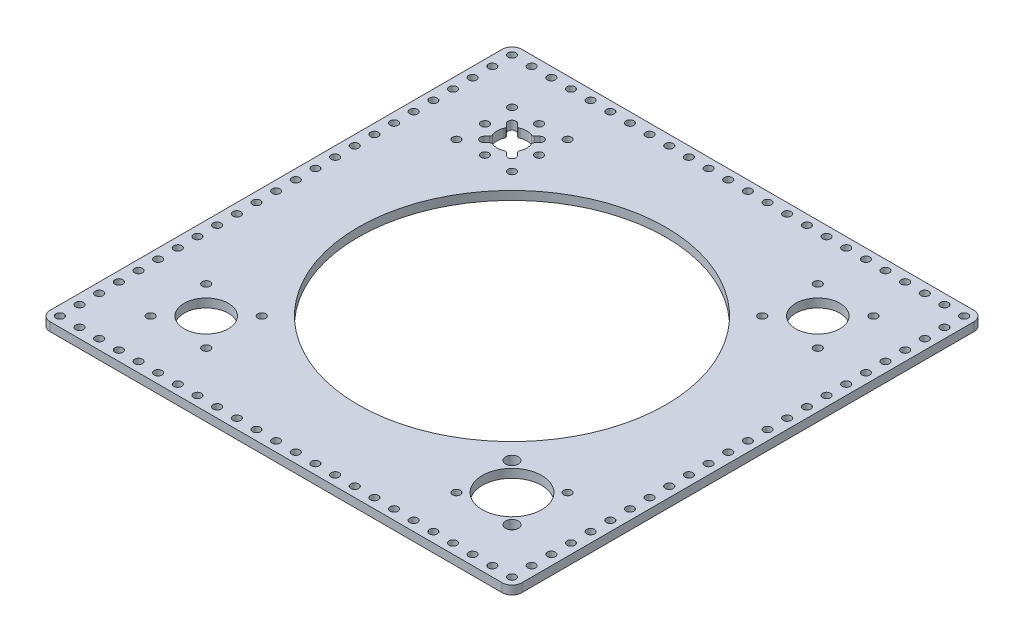
from build123d import *

# Parameters (mm, degrees)
SKETCH1_R           = 99.375000001
SKETCH1_R_2         = 2.5527
SKETCH1_R_3         = 19.177
SKETCH1_R_4         = 4.1275
SKETCH1_R_5         = 14.28115
ANDYMARK_BASE_DEPTH = 5.588


with BuildPart() as part:
    # Sketch1 → AndyMark Base (new body)
    with BuildSketch(Plane.XZ):
        with BuildLine():
            Line((0, -6.35), (0, -298.45))
            ThreePointArc((0, -298.45), (1.859871939, -302.940128061), (6.35, -304.8))
            Line((6.35, -304.8), (298.45, -304.8))
            ThreePointArc((298.45, -304.8), (302.940128061, -302.940128061), (304.8, -298.45))
            Line((304.8, -298.45), (304.8, -6.35))
            ThreePointArc((304.8, -6.35), (302.940128061, -1.859871939), (298.45, 0))
            Line((298.45, 0), (6.35, 0))
            ThreePointArc((6.35, 0), (1.859871939, -1.859871939), (0, -6.35))
        make_face()
        with Locations((152.4, -152.4)):
            Circle(SKETCH1_R, mode=Mode.SUBTRACT)
        with Locations((6.35, -298.45)):
            Circle(SKETCH1_R_2, mode=Mode.SUBTRACT)
        with Locations((19.05, -298.45)):
            Circle(SKETCH1_R_2, mode=Mode.SUBTRACT)
        with Locations((31.75, -298.45)):
            Circle(SKETCH1_R_2, mode=Mode.SUBTRACT)
        with Locations((44.45, -298.45)):
            Circle(SKETCH1_R_2, mode=Mode.SUBTRACT)
        with Locations((57.15, -298.45)):
            Circle(SKETCH1_R_2, mode=Mode.SUBTRACT)
        with Locations((69.85, -298.45)):
            Circle(SKETCH1_R_2, mode=Mode.SUBTRACT)
        with Locations((82.55, -298.45)):
            Circle(SKETCH1_R_2, mode=Mode.SUBTRACT)
        with Locations((95.25, -298.45)):
            Circle(SKETCH1_R_2, mode=Mode.SUBTRACT)
        with Locations((107.95, -298.45)):
            Circle(SKETCH1_R_2, mode=Mode.SUBTRACT)
        with Locations((120.65, -298.45)):
            Circle(SKETCH1_R_2, mode=Mode.SUBTRACT)
        with Locations((133.35, -298.45)):
            Circle(SKETCH1_R_2, mode=Mode.SUBTRACT)
        with Locations((146.05, -298.45)):
            Circle(SKETCH1_R_2, mode=Mode.SUBTRACT)
        with Locations((158.75, -298.45)):
            Circle(SKETCH1_R_2, mode=Mode.SUBTRACT)
        with Locations((171.45, -298.45)):
            Circle(SKETCH1_R_2, mode=Mode.SUBTRACT)
        with Locations((184.15, -298.45)):
            Circle(SKETCH1_R_2, mode=Mode.SUBTRACT)
        with Locations((196.85, -298.45)):
            Circle(SKETCH1_R_2, mode=Mode.SUBTRACT)
        with Locations((209.55, -298.45)):
            Circle(SKETCH1_R_2, mode=Mode.SUBTRACT)
        with Locations((222.25, -298.45)):
            Circle(SKETCH1_R_2, mode=Mode.SUBTRACT)
        with Locations((234.95, -298.45)):
            Circle(SKETCH1_R_2, mode=Mode.SUBTRACT)
        with Locations((247.65, -298.45)):
            Circle(SKETCH1_R_2, mode=Mode.SUBTRACT)
        with Locations((260.35, -298.45)):
            Circle(SKETCH1_R_2, mode=Mode.SUBTRACT)
        with Locations((273.05, -298.45)):
            Circle(SKETCH1_R_2, mode=Mode.SUBTRACT)
        with Locations((285.75, -298.45)):
            Circle(SKETCH1_R_2, mode=Mode.SUBTRACT)
        with Locations((298.45, -298.45)):
            Circle(SKETCH1_R_2, mode=Mode.SUBTRACT)
        with Locations((6.35, -6.35)):
            Circle(SKETCH1_R_2, mode=Mode.SUBTRACT)
        with Locations((19.05, -6.35)):
            Circle(SKETCH1_R_2, mode=Mode.SUBTRACT)
        with Locations((31.75, -6.35)):
            Circle(SKETCH1_R_2, mode=Mode.SUBTRACT)
        with Locations((44.45, -6.35)):
            Circle(SKETCH1_R_2, mode=Mode.SUBTRACT)
        with Locations((57.15, -6.35)):
            Circle(SKETCH1_R_2, mode=Mode.SUBTRACT)
        with Locations((69.85, -6.35)):
            Circle(SKETCH1_R_2, mode=Mode.SUBTRACT)
        with Locations((82.55, -6.35)):
            Circle(SKETCH1_R_2, mode=Mode.SUBTRACT)
        with Locations((95.25, -6.35)):
            Circle(SKETCH1_R_2, mode=Mode.SUBTRACT)
        with Locations((107.95, -6.35)):
            Circle(SKETCH1_R_2, mode=Mode.SUBTRACT)
        with Locations((120.65, -6.35)):
            Circle(SKETCH1_R_2, mode=Mode.SUBTRACT)
        with Locations((133.35, -6.35)):
            Circle(SKETCH1_R_2, mode=Mode.SUBTRACT)
        with Locations((146.05, -6.35)):
            Circle(SKETCH1_R_2, mode=Mode.SUBTRACT)
        with Locations((158.75, -6.35)):
            Circle(SKETCH1_R_2, mode=Mode.SUBTRACT)
        with Locations((171.45, -6.35)):
            Circle(SKETCH1_R_2, mode=Mode.SUBTRACT)
        with Locations((184.15, -6.35)):
            Circle(SKETCH1_R_2, mode=Mode.SUBTRACT)
        with Locations((196.85, -6.35)):
            Circle(SKETCH1_R_2, mode=Mode.SUBTRACT)
        with Locations((209.55, -6.35)):
            Circle(SKETCH1_R_2, mode=Mode.SUBTRACT)
        with Locations((222.25, -6.35)):
            Circle(SKETCH1_R_2, mode=Mode.SUBTRACT)
        with Locations((234.95, -6.35)):
            Circle(SKETCH1_R_2, mode=Mode.SUBTRACT)
        with Locations((247.65, -6.35)):
            Circle(SKETCH1_R_2, mode=Mode.SUBTRACT)
        with Locations((260.35, -6.35)):
            Circle(SKETCH1_R_2, mode=Mode.SUBTRACT)
        with Locations((273.05, -6.35)):
            Circle(SKETCH1_R_2, mode=Mode.SUBTRACT)
        with Locations((285.75, -6.35)):
            Circle(SKETCH1_R_2, mode=Mode.SUBTRACT)
        with Locations((298.45, -6.35)):
            Circle(SKETCH1_R_2, mode=Mode.SUBTRACT)
        with Locations((6.35, -285.75)):
            Circle(SKETCH1_R_2, mode=Mode.SUBTRACT)
        with Locations((298.45, -285.75)):
            Circle(SKETCH1_R_2, mode=Mode.SUBTRACT)
        with Locations((6.35, -273.05)):
            Circle(SKETCH1_R_2, mode=Mode.SUBTRACT)
        with Locations((298.45, -273.05)):
            Circle(SKETCH1_R_2, mode=Mode.SUBTRACT)
        with Locations((6.35, -260.35)):
            Circle(SKETCH1_R_2, mode=Mode.SUBTRACT)
        with Locations((298.45, -260.35)):
            Circle(SKETCH1_R_2, mode=Mode.SUBTRACT)
        with Locations((6.35, -247.65)):
            Circle(SKETCH1_R_2, mode=Mode.SUBTRACT)
        with Locations((298.45, -247.65)):
            Circle(SKETCH1_R_2, mode=Mode.SUBTRACT)
        with Locations((6.35, -234.95)):
            Circle(SKETCH1_R_2, mode=Mode.SUBTRACT)
        with Locations((298.45, -234.95)):
            Circle(SKETCH1_R_2, mode=Mode.SUBTRACT)
        with Locations((6.35, -222.25)):
            Circle(SKETCH1_R_2, mode=Mode.SUBTRACT)
        with Locations((298.45, -222.25)):
            Circle(SKETCH1_R_2, mode=Mode.SUBTRACT)
        with Locations((6.35, -209.55)):
            Circle(SKETCH1_R_2, mode=Mode.SUBTRACT)
        with Locations((298.45, -209.55)):
            Circle(SKETCH1_R_2, mode=Mode.SUBTRACT)
        with Locations((6.35, -196.85)):
            Circle(SKETCH1_R_2, mode=Mode.SUBTRACT)
        with Locations((298.45, -196.85)):
            Circle(SKETCH1_R_2, mode=Mode.SUBTRACT)
        with Locations((6.35, -184.15)):
            Circle(SKETCH1_R_2, mode=Mode.SUBTRACT)
        with Locations((298.45, -184.15)):
            Circle(SKETCH1_R_2, mode=Mode.SUBTRACT)
        with Locations((6.35, -171.45)):
            Circle(SKETCH1_R_2, mode=Mode.SUBTRACT)
        with Locations((298.45, -171.45)):
            Circle(SKETCH1_R_2, mode=Mode.SUBTRACT)
        with Locations((6.35, -158.75)):
            Circle(SKETCH1_R_2, mode=Mode.SUBTRACT)
        with Locations((298.45, -158.75)):
            Circle(SKETCH1_R_2, mode=Mode.SUBTRACT)
        with Locations((6.35, -146.05)):
            Circle(SKETCH1_R_2, mode=Mode.SUBTRACT)
        with Locations((298.45, -146.05)):
            Circle(SKETCH1_R_2, mode=Mode.SUBTRACT)
        with Locations((6.35, -133.35)):
            Circle(SKETCH1_R_2, mode=Mode.SUBTRACT)
        with Locations((298.45, -133.35)):
            Circle(SKETCH1_R_2, mode=Mode.SUBTRACT)
        with Locations((6.35, -120.65)):
            Circle(SKETCH1_R_2, mode=Mode.SUBTRACT)
        with Locations((298.45, -120.65)):
            Circle(SKETCH1_R_2, mode=Mode.SUBTRACT)
        with Locations((6.35, -107.95)):
            Circle(SKETCH1_R_2, mode=Mode.SUBTRACT)
        with Locations((298.45, -107.95)):
            Circle(SKETCH1_R_2, mode=Mode.SUBTRACT)
        with Locations((6.35, -95.25)):
            Circle(SKETCH1_R_2, mode=Mode.SUBTRACT)
        with Locations((298.45, -95.25)):
            Circle(SKETCH1_R_2, mode=Mode.SUBTRACT)
        with Locations((6.35, -82.55)):
            Circle(SKETCH1_R_2, mode=Mode.SUBTRACT)
        with Locations((298.45, -82.55)):
            Circle(SKETCH1_R_2, mode=Mode.SUBTRACT)
        with Locations((6.35, -69.85)):
            Circle(SKETCH1_R_2, mode=Mode.SUBTRACT)
        with Locations((298.45, -69.85)):
            Circle(SKETCH1_R_2, mode=Mode.SUBTRACT)
        with Locations((6.35, -57.15)):
            Circle(SKETCH1_R_2, mode=Mode.SUBTRACT)
        with Locations((298.45, -57.15)):
            Circle(SKETCH1_R_2, mode=Mode.SUBTRACT)
        with Locations((6.35, -44.45)):
            Circle(SKETCH1_R_2, mode=Mode.SUBTRACT)
        with Locations((298.45, -44.45)):
            Circle(SKETCH1_R_2, mode=Mode.SUBTRACT)
        with Locations((6.35, -31.75)):
            Circle(SKETCH1_R_2, mode=Mode.SUBTRACT)
        with Locations((298.45, -31.75)):
            Circle(SKETCH1_R_2, mode=Mode.SUBTRACT)
        with Locations((6.35, -19.05)):
            Circle(SKETCH1_R_2, mode=Mode.SUBTRACT)
        with Locations((298.45, -19.05)):
            Circle(SKETCH1_R_2, mode=Mode.SUBTRACT)
        with Locations((35.656670426, -35.656670426)):
            Circle(SKETCH1_R_2, mode=Mode.SUBTRACT)
        with Locations((71.57769491, -35.656670426)):
            Circle(SKETCH1_R_2, mode=Mode.SUBTRACT)
        with Locations((71.57769491, -71.57769491)):
            Circle(SKETCH1_R_2, mode=Mode.SUBTRACT)
        with Locations((269.143329574, -71.57769491)):
            Circle(SKETCH1_R_2, mode=Mode.SUBTRACT)
        with Locations((233.22230509, -35.656670426)):
            Circle(SKETCH1_R_2, mode=Mode.SUBTRACT)
        with Locations((269.143329574, -233.22230509)):
            Circle(SKETCH1_R_2, mode=Mode.SUBTRACT)
        with Locations((269.143329574, -269.143329574)):
            Circle(SKETCH1_R_2, mode=Mode.SUBTRACT)
        with Locations((233.22230509, -269.143329574)):
            Circle(SKETCH1_R_2, mode=Mode.SUBTRACT)
        with Locations((35.656670426, -269.143329574)):
            Circle(SKETCH1_R_2, mode=Mode.SUBTRACT)
        with Locations((35.656670426, -71.57769491)):
            Circle(SKETCH1_R_2, mode=Mode.SUBTRACT)
        with Locations((233.22230509, -233.22230509)):
            Circle(SKETCH1_R_2, mode=Mode.SUBTRACT)
        with Locations((35.656670426, -233.22230509)):
            Circle(SKETCH1_R_2, mode=Mode.SUBTRACT)
        with Locations((71.57769491, -233.22230509)):
            Circle(SKETCH1_R_2, mode=Mode.SUBTRACT)
        with Locations((71.57769491, -269.143329574)):
            Circle(SKETCH1_R_2, mode=Mode.SUBTRACT)
        with Locations((251.182817332, -53.617182668)):
            Circle(SKETCH1_R_3, mode=Mode.SUBTRACT)
        with Locations((233.22230509, -71.57769491)):
            Circle(SKETCH1_R_4, mode=Mode.SUBTRACT)
        with Locations((269.143329574, -35.656670426)):
            Circle(SKETCH1_R_4, mode=Mode.SUBTRACT)
        with Locations((251.182817332, -251.182817332)):
            Circle(SKETCH1_R_5, mode=Mode.SUBTRACT)
        with Locations((53.617182668, -53.617182668)):
            Circle(SKETCH1_R_5, mode=Mode.SUBTRACT)
        with Locations((53.617182668, -268.645317332)):
            Circle(SKETCH1_R_2, mode=Mode.SUBTRACT)
        with Locations((71.079682668, -251.182817332)):
            Circle(SKETCH1_R_2, mode=Mode.SUBTRACT)
        with Locations((53.617182668, -233.720317332)):
            Circle(SKETCH1_R_2, mode=Mode.SUBTRACT)
        with Locations((36.154682668, -251.182817332)):
            Circle(SKETCH1_R_2, mode=Mode.SUBTRACT)
        with BuildLine():
            Line((62.762572449, -256.718144152), (64.40247027, -258.358041972))
            ThreePointArc((64.40247027, -258.358041972), (64.40247027, -261.968104933), (60.792407309, -261.968104933))
            Line((60.792407309, -261.968104933), (59.152509488, -260.328207113))
            ThreePointArc((59.152509488, -260.328207113), (58.32939993, -259.891732251), (57.403160029, -259.992227509))
            ThreePointArc((57.403160029, -259.992227509), (53.617182668, -260.771317332), (49.831205307, -259.992227509))
            ThreePointArc((49.831205307, -259.992227509), (48.904965407, -259.891732251), (48.081855848, -260.328207113))
            Line((48.081855848, -260.328207113), (46.441958028, -261.968104933))
            ThreePointArc((46.441958028, -261.968104933), (42.831895067, -261.968104933), (42.831895067, -258.358041972))
            Line((42.831895067, -258.358041972), (44.471792887, -256.718144152))
            ThreePointArc((44.471792887, -256.718144152), (44.908267749, -255.895034593), (44.807772491, -254.968794693))
            ThreePointArc((44.807772491, -254.968794693), (44.028682668, -251.182817332), (44.807772491, -247.396839971))
            ThreePointArc((44.807772491, -247.396839971), (44.908267749, -246.47060007), (44.471792887, -245.647490512))
            Line((44.471792887, -245.647490512), (42.831895067, -244.007592691))
            ThreePointArc((42.831895067, -244.007592691), (42.831895067, -240.39752973), (46.441958028, -240.39752973))
            Line((46.441958028, -240.39752973), (48.081855848, -242.037427551))
            ThreePointArc((48.081855848, -242.037427551), (48.904965407, -242.473902413), (49.831205307, -242.373407155))
            ThreePointArc((49.831205307, -242.373407155), (53.617182668, -241.594317332), (57.403160029, -242.373407155))
            ThreePointArc((57.403160029, -242.373407155), (58.32939993, -242.473902413), (59.152509488, -242.037427551))
            Line((59.152509488, -242.037427551), (60.792407309, -240.39752973))
            ThreePointArc((60.792407309, -240.39752973), (64.40247027, -240.39752973), (64.40247027, -244.007592691))
            Line((64.40247027, -244.007592691), (62.762572449, -245.647490512))
            ThreePointArc((62.762572449, -245.647490512), (62.326097587, -246.47060007), (62.426592845, -247.396839971))
            ThreePointArc((62.426592845, -247.396839971), (63.205682668, -251.182817332), (62.426592845, -254.968794693))
            ThreePointArc((62.426592845, -254.968794693), (62.326097587, -255.895034593), (62.762572449, -256.718144152))
        make_face(mode=Mode.SUBTRACT)
    extrude(amount=-ANDYMARK_BASE_DEPTH)


solid = part.part
